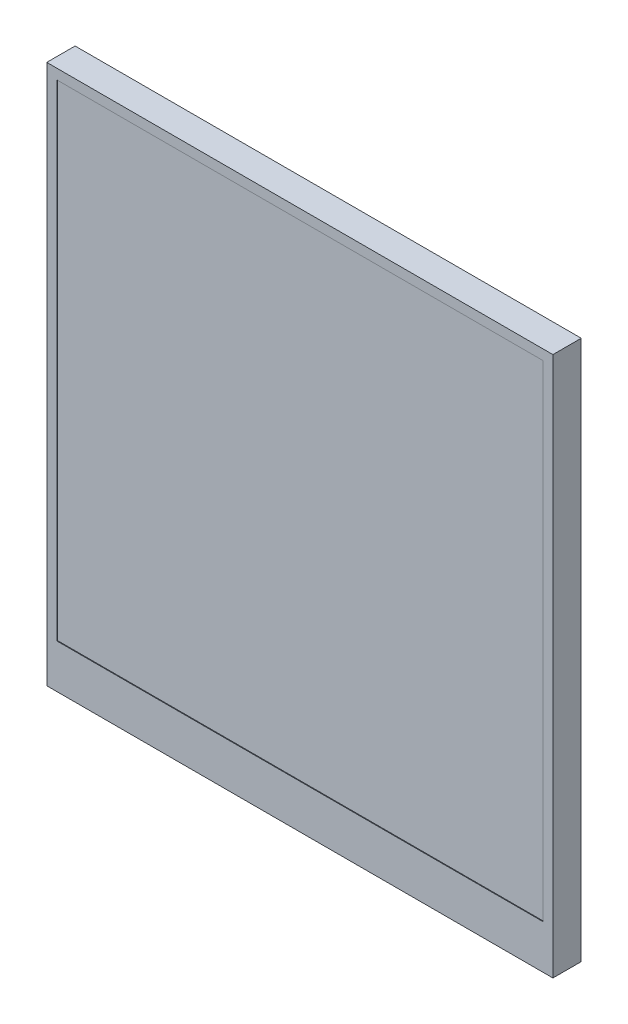
from build123d import *

# Parameters (mm, degrees)
SKETCH1_W           = 75
SKETCH1_H           = 80
BOSS_EXTRUDE1_DEPTH = 4.2
SKETCH2_W           = 72
SKETCH2_H           = 72
CUT_EXTRUDE1_DEPTH  = 0.1
SKETCH3_R           = 3
SKETCH3_R_2         = 1.35
BOSS_EXTRUDE2_DEPTH = 2


with BuildPart() as part:
    # Sketch1 → Boss-Extrude1 (new body)
    with BuildSketch(Plane.XY):
        with Locations((37.5, 40)):
            Rectangle(SKETCH1_W, SKETCH1_H)
    extrude(amount=BOSS_EXTRUDE1_DEPTH)

    # Sketch2 → Cut-Extrude1 (cut)
    with BuildSketch(Plane.XY.offset(4.2)):
        with Locations((37.5, 42.5)):
            Rectangle(SKETCH2_W, SKETCH2_H)
    extrude(amount=-CUT_EXTRUDE1_DEPTH, mode=Mode.SUBTRACT)

    # Sketch3 → Boss-Extrude2 (add)
    with BuildSketch(Plane(origin=(0, 0, 0), x_dir=(-1, 0, 0), z_dir=(0, 0, -1))):
        with Locations((-61.5, 75)):
            Circle(SKETCH3_R)
        with Locations((-61.5, 75)):
            Circle(SKETCH3_R_2, mode=Mode.SUBTRACT)
        with Locations((-3.5, 75)):
            Circle(SKETCH3_R)
        with Locations((-3.5, 75)):
            Circle(SKETCH3_R_2, mode=Mode.SUBTRACT)
        with Locations((-3.5, 26)):
            Circle(SKETCH3_R)
        with Locations((-3.5, 26)):
            Circle(SKETCH3_R_2, mode=Mode.SUBTRACT)
        with Locations((-61.5, 26)):
            Circle(SKETCH3_R)
        with Locations((-61.5, 26)):
            Circle(SKETCH3_R_2, mode=Mode.SUBTRACT)
    extrude(amount=BOSS_EXTRUDE2_DEPTH)


solid = part.part
